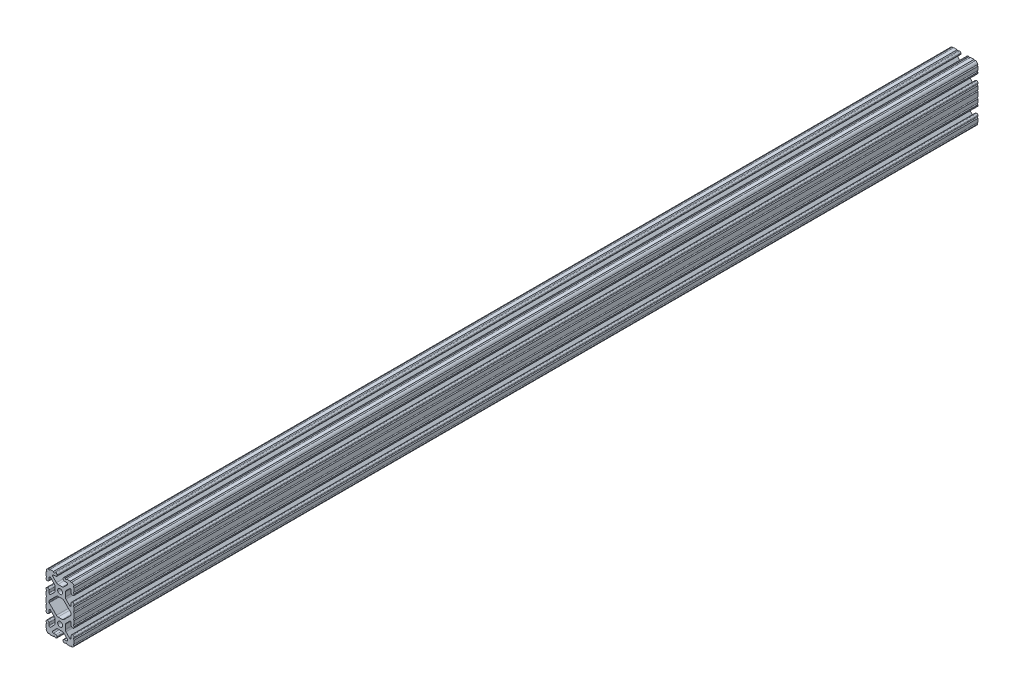
from build123d import *

# Parameters (mm, degrees)
BOSS_EXTRUDE1_DEPTH     = 609.6
SKETCH5_R               = 1.016
CUT_EXTRUDE1_DEPTH      = 610.6
CUT_EXTRUDE1_DEPTH_BACK = 610.6
BOSS_EXTRUDE2_DEPTH     = 609.6
CUT_EXTRUDE2_DEPTH      = 610.6
CUT_EXTRUDE2_DEPTH_BACK = 610.6


with BuildPart() as part:
    # Sketch4 → Boss-Extrude1 (new body, symmetric)
    with BuildSketch(Plane.XY):
        with BuildLine():
            Line((5.7912, -38.1), (14.3002, -38.1))
            ThreePointArc((14.3002, -38.1), (17.658815789, -36.708815789), (19.05, -33.3502))
            Line((19.05, -33.3502), (19.05, -24.8412))
            ThreePointArc((19.05, -24.8412), (18.544114832, -23.619885168), (17.3228, -23.114))
            Line((17.3228, -23.114), (16.7132, -23.114))
            ThreePointArc((16.7132, -23.114), (15.491885168, -23.619885168), (14.986, -24.8412))
            Line((14.986, -24.8412), (14.986, -28.046305235))
            ThreePointArc((14.986, -28.046305235), (14.189232738, -29.238751711), (12.782646215, -28.958964256))
            Line((12.782646215, -28.958964256), (7.888897763, -24.065215804))
            ThreePointArc((7.888897763, -24.065215804), (7.219915375, -23.064012907), (6.985, -21.883013566))
            Line((6.985, -21.883013566), (6.985, -19.05))
            Line((6.985, -19.05), (3.3274, -19.05))
            ThreePointArc((3.3274, -19.05), (2.352827104, -21.402827104), (0, -22.3774))
            Line((0, -22.3774), (0, -26.035))
            Line((0, -26.035), (2.833013566, -26.035))
            ThreePointArc((2.833013566, -26.035), (4.014012907, -26.269915375), (5.015215804, -26.938897763))
            Line((5.015215804, -26.938897763), (9.908964256, -31.832646215))
            ThreePointArc((9.908964256, -31.832646215), (10.188751711, -33.239232738), (8.996305235, -34.036))
            Line((8.996305235, -34.036), (5.7912, -34.036))
            ThreePointArc((5.7912, -34.036), (4.569885168, -34.541885168), (4.064, -35.7632))
            Line((4.064, -35.7632), (4.064, -36.3728))
            ThreePointArc((4.064, -36.3728), (4.569885168, -37.594114832), (5.7912, -38.1))
        make_face()
    extrude(amount=BOSS_EXTRUDE1_DEPTH, both=True)

    # Sketch5 → Cut-Extrude1 (cut, two sides)
    with BuildSketch(Plane.XY) as cut_extrude1_sk:
        with Locations((14.739477062, -38.1)):
            Circle(SKETCH5_R)
        with Locations((7.980305235, -38.1)):
            Circle(SKETCH5_R)
        with Locations((19.05, -33.789477062)):
            Circle(SKETCH5_R)
        with Locations((19.05, -27.030305235)):
            Circle(SKETCH5_R)
    extrude(amount=CUT_EXTRUDE1_DEPTH, mode=Mode.SUBTRACT)
    extrude(cut_extrude1_sk.sketch, amount=-CUT_EXTRUDE1_DEPTH_BACK, mode=Mode.SUBTRACT)

    # Mirror1: part across plane


with BuildPart() as part_1:
    add(part.part)
    add(part.part.mirror(Plane(origin=(6.985, -19.05, 609.6), x_dir=(0, 0, 1), z_dir=(0, -1, 0))))

    # Sketch6 → Boss-Extrude2 (add, symmetric)
    with BuildSketch(Plane.XY):
        with BuildLine():
            Line((19.05, -3.294522938), (19.05, 0))
            Line((19.05, 0), (13.723477062, 0))
            Line((13.723477062, 0), (13.723477062, -4.310522938))
            Line((13.723477062, -4.310522938), (18.034, -4.310522938))
            ThreePointArc((18.034, -4.310522938), (18.33157951, -3.592102448), (19.05, -3.294522938))
        make_face()
    extrude(amount=BOSS_EXTRUDE2_DEPTH, both=True)

    # Sketch7 → Cut-Extrude2 (cut, two sides)
    with BuildSketch(Plane.XY) as cut_extrude2_sk:
        with BuildLine():
            Line((7.46209003, -8.714228011), (14.68842049, -1.487897552))
            ThreePointArc((14.68842049, -1.487897552), (14.908661605, -1.158283429), (14.986, -0.769477062))
            Line((14.986, -0.769477062), (14.986, 0))
            Line((14.986, 0), (0, 0))
            Line((0, 0), (7.46209003, -8.714228011))
        make_face()
    extrude(amount=CUT_EXTRUDE2_DEPTH, mode=Mode.SUBTRACT)
    extrude(cut_extrude2_sk.sketch, amount=-CUT_EXTRUDE2_DEPTH_BACK, mode=Mode.SUBTRACT)

    # Mirror2: part across plane


with BuildPart() as part_2:
    add(part_1.part)
    add(part_1.part.mirror(Plane.ZX))

    # Mirror3: part across plane


with BuildPart() as part_3:
    add(part_2.part)
    add(part_2.part.mirror(Plane(origin=(0, 0, 0), x_dir=(0, 0, 1), z_dir=(1, 0, 0))))


solid = part_3.part
